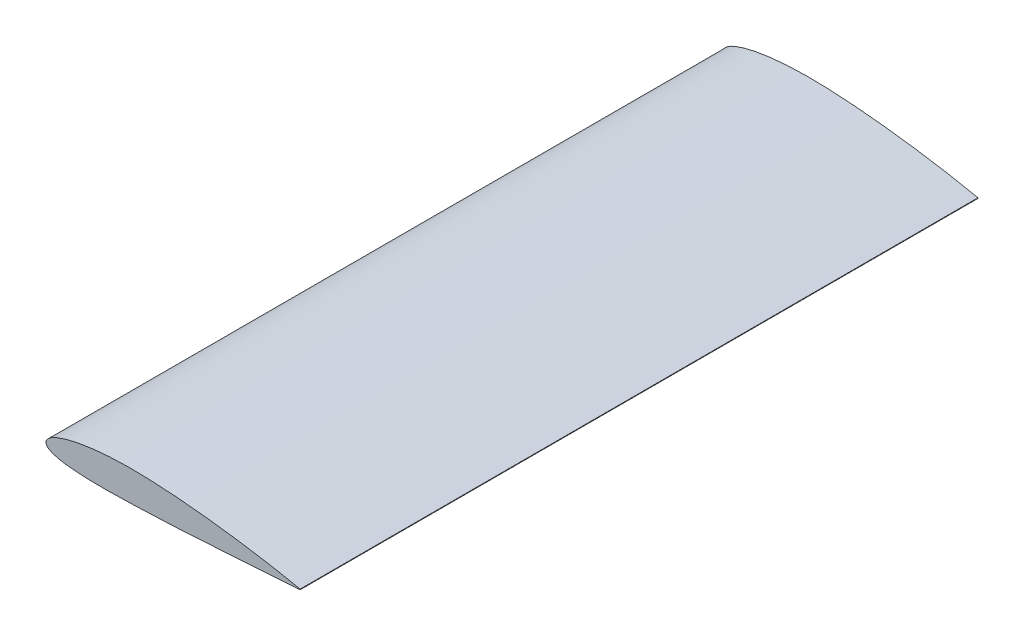
from build123d import *

# Parameters (mm, degrees)
RESSALTO_EXTRUS_O1_DEPTH = 2000


with BuildPart() as part:
    # Esboço2 → Ressalto-extrusão1 (new body, symmetric)
    with BuildSketch(Plane.XY):
        with BuildLine():
            Line((1499.874, -1.8855), (1500.126, 1.8855))
            add(Edge.make_bspline(
                [(1500.126, 1.8855), (1499.362509627, 2.044546226), (1496.312880245, 2.679828689), (1489.468154358, 4.100504681), (1478.104245283, 6.438828426), (1462.285881607, 9.648723476), (1442.106500152, 13.677067413), (1417.682616132, 18.448809163), (1389.157636805, 23.881625123), (1356.699510592, 29.887226277), (1320.49931465, 36.363378584), (1280.77334318, 43.20922537), (1237.758283256, 50.321149605), (1191.712196128, 57.58970568), (1142.912668882, 64.907951577), (1091.656503495, 72.170784317), (1038.255293936, 79.26933002), (983.035531079, 86.098556761), (926.336368804, 92.560783205), (868.506926853, 98.542914584), (809.905975551, 103.957990529), (750.897541128, 108.696716696), (691.8509012, 112.681641218), (633.068914467, 115.818515442), (574.833601038, 118.066588321), (517.503711061, 119.012387707), (461.524793157, 118.648451295), (407.352172284, 116.966390015), (355.343945044, 113.986576207), (305.844137276, 109.753318192), (259.177510516, 104.341080513), (215.649043973, 97.840707188), (175.537823011, 90.367217662), (139.097633545, 82.047336516), (106.548459136, 73.030192936), (78.082932558, 63.45504798), (53.851542241, 53.474002404), (33.967275762, 43.219910956), (18.47971175, 32.794557512), (7.397666117, 22.21969789), (0.728284058, 11.285063424), (-0.85520489, -0.085656266), (2.943648711, -10.90799301), (11.576569643, -20.316733659), (24.385486658, -28.555121219), (41.366215214, -35.890840198), (62.490343267, -42.361335595), (87.669431066, -47.973900932), (116.765810868, -52.714264349), (149.60825776, -56.578167734), (185.999759166, -59.571815988), (225.723270873, -61.720478149), (268.544933173, -63.058421283), (314.215134318, -63.641384481), (362.470919866, -63.532647232), (413.036025516, -62.81848636), (465.622461548, -61.585908647), (519.930965328, -59.941893383), (575.737900188, -57.973066455), (632.789188171, -55.816868209), (690.733841298, -53.209380553), (749.136590231, -50.28111843), (807.576269289, -47.095896718), (865.698253904, -43.744219053), (923.147646701, -40.287026002), (979.571962894, -36.791814269), (1034.623247648, -33.30336298), (1087.961311983, -29.87076952), (1139.25459981, -26.530801711), (1188.182906745, -23.311726447), (1234.438975863, -20.243133486), (1277.731797001, -17.341344342), (1317.787405797, -14.635336351), (1354.351295363, -12.138592146), (1387.189794891, -9.874970035), (1416.092684642, -7.860770047), (1440.873976799, -6.115244349), (1461.37342314, -4.659928887), (1477.457683524, -3.506556244), (1489.022197516, -2.674230183), (1495.991011959, -2.1676645), (1499.096499892, -1.941998482), (1499.874, -1.8855)],
                knots=[0, 0, 0, 0, 0.000764172, 0.003052354, 0.006849806, 0.012132473, 0.018867992, 0.027012839, 0.036516812, 0.047320748, 0.059356871, 0.072550805, 0.086820052, 0.102077398, 0.118227703, 0.135170889, 0.152802297, 0.171012918, 0.18968989, 0.20871821, 0.227978895, 0.247353901, 0.266722825, 0.285966043, 0.30503218, 0.323824437, 0.342143817, 0.359879711, 0.376925818, 0.393181853, 0.408552719, 0.422951453, 0.436298149, 0.448522824, 0.459565428, 0.469379445, 0.477933616, 0.485220338, 0.491267538, 0.496167824, 0.50013339, 0.503587222, 0.507040597, 0.511000028, 0.515876125, 0.521872239, 0.529071215, 0.537494991, 0.547131181, 0.557945451, 0.569889642, 0.582904388, 0.596921672, 0.611866369, 0.627656322, 0.64420424, 0.661417059, 0.679197208, 0.697442956, 0.716133923, 0.735139063, 0.75427754, 0.773432072, 0.792486537, 0.811323416, 0.82982615, 0.847880344, 0.865374073, 0.882198025, 0.89824695, 0.913420544, 0.927622056, 0.940762976, 0.952758838, 0.963532927, 0.973016418, 0.981148268, 0.987875252, 0.99315353, 0.996949037, 0.999236151, 1, 1, 1, 1], degree=3))
        make_face()
    extrude(amount=RESSALTO_EXTRUS_O1_DEPTH, both=True)


solid = part.part
